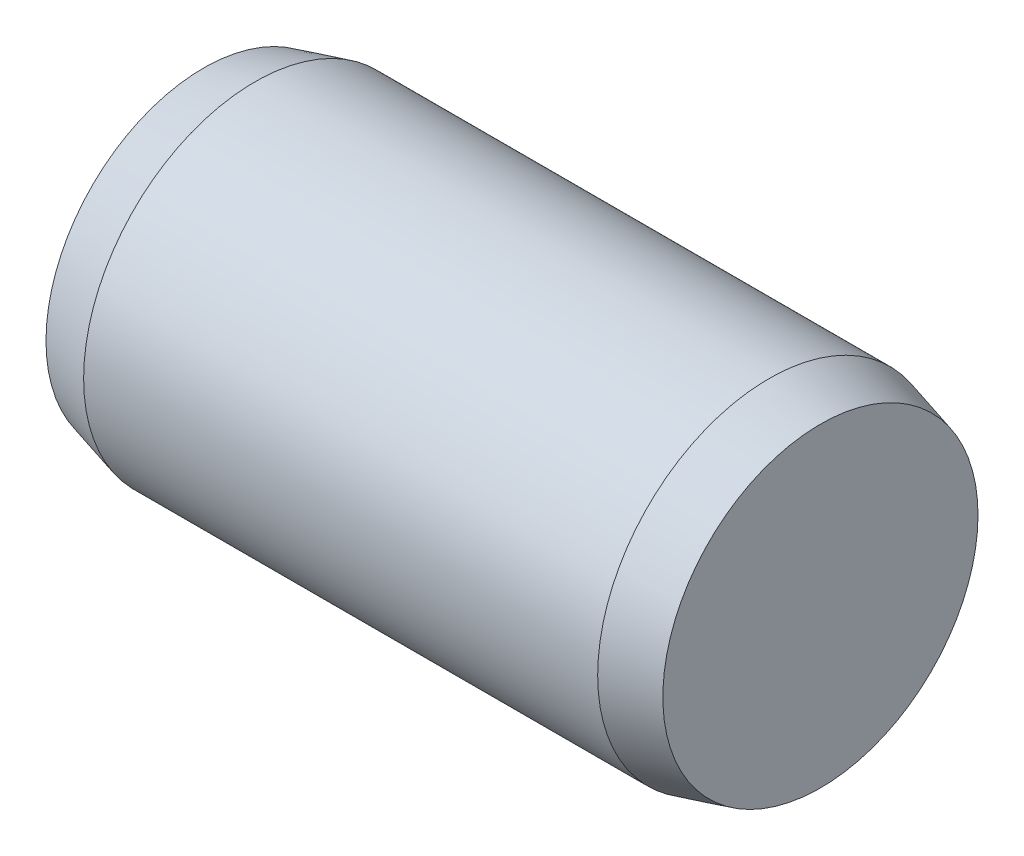
from build123d import *

# Parameters (mm, degrees)
SKETCH2_R           = 2
EXTRUDE1_DEPTH      = 3
EXTRUDE1_DEPTH_BACK = 3
SKETCH3_R           = 2
EXTRUDE2_DEPTH      = 0.6
EXTRUDE2_TAPER      = 15
SKETCH4_R           = 2
EXTRUDE3_DEPTH      = 0.6
EXTRUDE3_TAPER      = 15


with BuildPart() as part:
    # Sketch2 → Extrude1 (new body, two sides)
    with BuildSketch(Plane(origin=(0, 0, 0), x_dir=(0, 0, -1), z_dir=(1, 0, 0))) as extrude1_sk:
        Circle(SKETCH2_R)
    extrude(amount=EXTRUDE1_DEPTH)
    extrude(extrude1_sk.sketch, amount=-EXTRUDE1_DEPTH_BACK)

    # Sketch3 → Extrude2 (add)
    with BuildSketch(Plane(origin=(3, 0, 0), x_dir=(0, 0, -1), z_dir=(1, 0, 0))):
        Circle(SKETCH3_R)
    extrude(amount=EXTRUDE2_DEPTH, taper=EXTRUDE2_TAPER)

    # Sketch4 → Extrude3 (add)
    with BuildSketch(Plane.ZY.offset(3)):
        Circle(SKETCH4_R)
    extrude(amount=EXTRUDE3_DEPTH, taper=EXTRUDE3_TAPER)


solid = part.part
